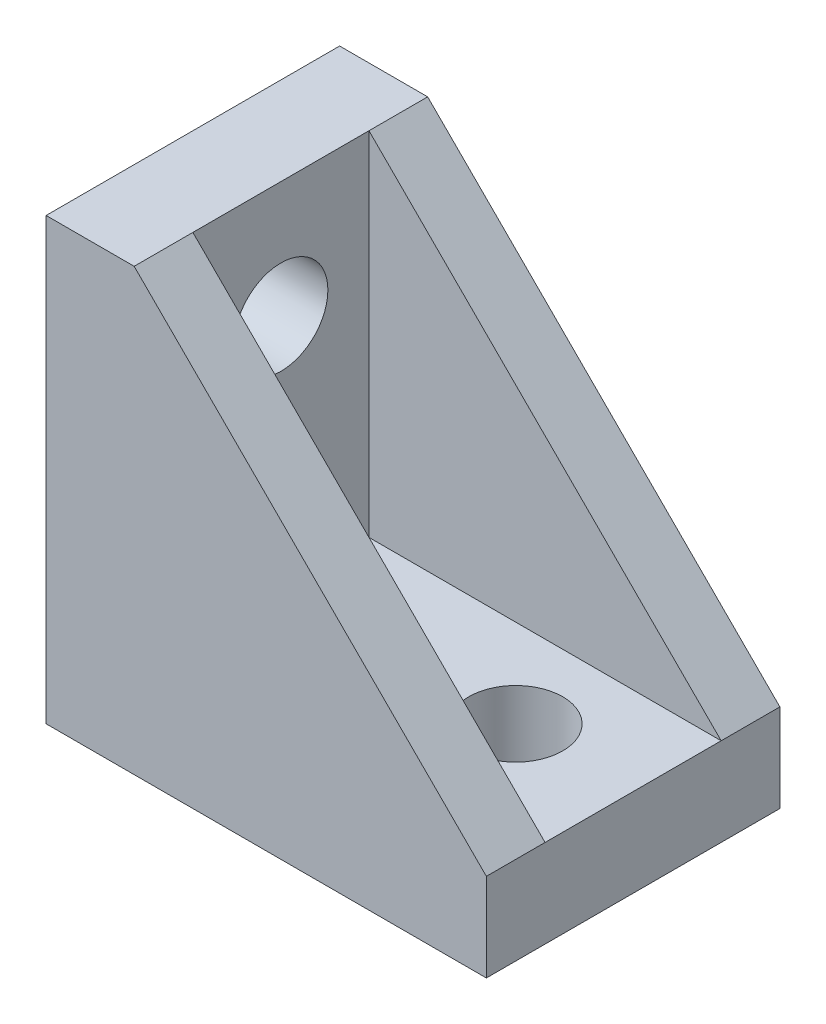
from build123d import *

# Parameters (mm, degrees)
BOSS_EXTRUDE1_DEPTH = 3
BOSS_EXTRUDE3_DEPTH = 2
SKETCH2_R           = 1.6
CUT_EXTRUDE1_DEPTH  = 21.808652047


with BuildPart() as part:
    # Sketch1 → Boss-Extrude1 (new body)
    with BuildSketch(Plane.XY):
        Polygon((0, 0), (15, 0), (15, 3), (3, 3), (3, 15), (0, 15), align=None)
    extrude(amount=BOSS_EXTRUDE1_DEPTH)

    # Sketch1_4 → Boss-Extrude3 (add)
    with BuildSketch(Plane.XY):
        Polygon((0, 0), (15, 0), (15, 3), (3, 15), (0, 15), align=None)
    extrude(amount=-BOSS_EXTRUDE3_DEPTH)

    # Mirror1: part across plane


with BuildPart() as part_1:
    add(part.part)
    add(part.part.mirror(Plane.XY.offset(3)))

    # Sketch2 → Cut-Extrude1 (cut, through all)
    with BuildSketch(Plane(origin=(3, 0, 0), x_dir=(0, 0, -1), z_dir=(1, 0, 0))):
        with Locations((-3, 11)):
            Circle(SKETCH2_R)
    cut_extrude1 = extrude(amount=-CUT_EXTRUDE1_DEPTH, mode=Mode.SUBTRACT)

    # Mirror2: Cut-Extrude1 across plane
    add(cut_extrude1.mirror(Plane(origin=(0, 0, 0), x_dir=(0, 0, 1), z_dir=(0.7071067811865517, -0.7071067811865436, 0))), mode=Mode.SUBTRACT)


solid = part_1.part
